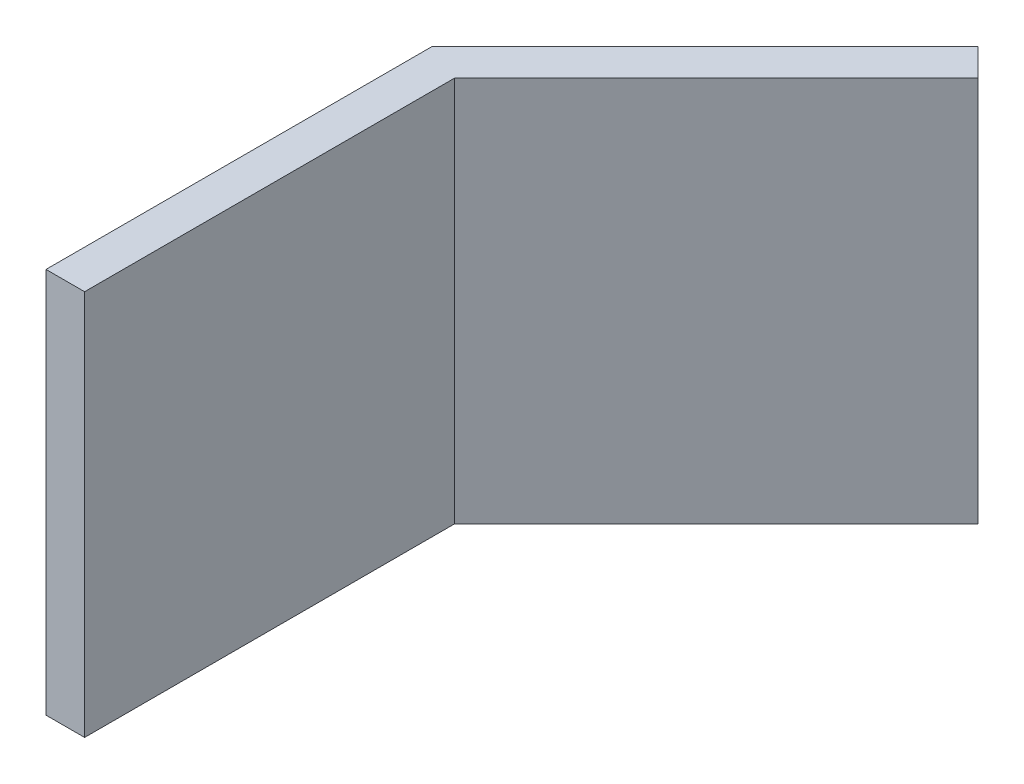
from build123d import *

# Parameters (mm, degrees)
EXTRUSION1_DEPTH = 20


with BuildPart() as part:
    # Esquisse1 → Extrusion1 (new body)
    with BuildSketch(Plane(origin=(0, 0, 0), x_dir=(1, 0, 0), z_dir=(0, 1, 0))):
        Polygon((0, 0), (0, 20), (14.142135624, 34.142135624), (15.556349186, 32.727922061), (2, 19.171572875), (2, 0), align=None)
    extrude(amount=EXTRUSION1_DEPTH)


solid = part.part
